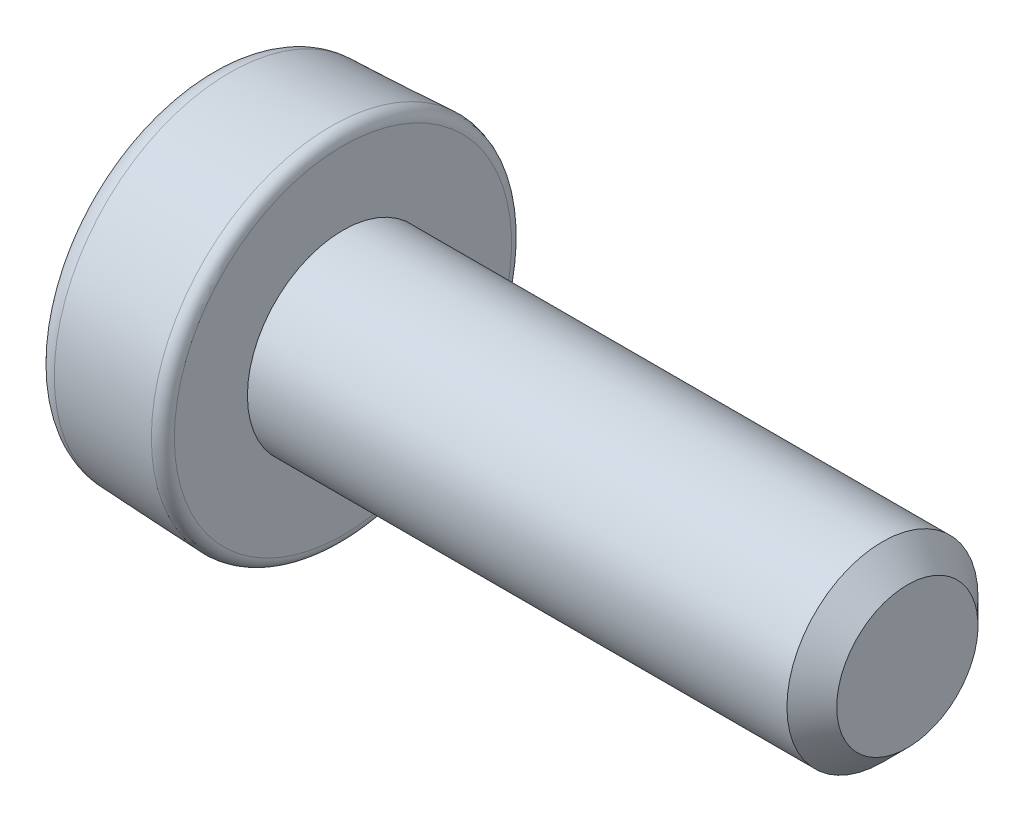
from build123d import *

# Parameters (mm, degrees)
ESQUISSE2_W                  = 0.3
ESQUISSE2_H                  = 0.8
EXTRUSION1_DEPTH             = 0.3
R_P_TITION_CIRCULAIRE1_COUNT = 4
CHANFREIN1_SIZE              = 0.2


with BuildPart() as part:
    # Esquisse1 → Révolution1 (revolve)
    with BuildSketch(Plane.XY, mode=Mode.PRIVATE) as r_volution1_sk:
        with BuildLine():
            Line((5.021607474, 0), (5.021607474, 0.628392526))
            Line((5.021607474, 0.628392526), (4.8, 0.85))
            Line((4.8, 0.85), (0, 0.85))
            Line((0, 0.85), (0, 1.50010144))
            ThreePointArc((0, 1.50010144), (-0.030899737, 1.572386664), (-0.104503073, 1.6))
            Line((-0.104503073, 1.6), (-1.009006147, 1.559228203))
            ThreePointArc((-1.009006147, 1.559228203), (-1.144570449, 1.497631608), (-1.2, 1.359431083))
            Line((-1.2, 1.359431083), (-1.2, 0))
            Line((-1.2, 0), (5.021607474, 0))
        make_face()
    revolve(r_volution1_sk.sketch.rotate(Axis((-2.783918663, 0, 0), (1, 0, 0)), 90), axis=Axis((-2.783918663, 0, 0), (1, 0, 0)))  # turned: the seam where the file's is

    # Esquisse2 → Extrusion1 (cut)
    with BuildSketch(Plane.ZY.offset(1.2)):
        with Locations((0, 0.4)):
            Rectangle(ESQUISSE2_W, ESQUISSE2_H)
    extrusion1 = extrude(amount=-EXTRUSION1_DEPTH, mode=Mode.SUBTRACT)

    # Répétition circulaire1: Extrusion1 ×4 about axis
    r_p_tition_circulaire1_axis = Axis((0, 0, 0), (1, 0, 0))
    for i in range(1, R_P_TITION_CIRCULAIRE1_COUNT):
        add(extrusion1.rotate(r_p_tition_circulaire1_axis, i * 360 / R_P_TITION_CIRCULAIRE1_COUNT), mode=Mode.SUBTRACT)

    # Chanfrein1
    chanfrein1_edges = [part.edges().sort_by_distance(p)[0] for p in [
        (-1.05, 0.15, -0.15),
        (-1.05, 0.15, 0.15),
        (-1.05, -0.15, -0.15),
        (-1.05, -0.15, 0.15),
    ]]
    chamfer(chanfrein1_edges, length=CHANFREIN1_SIZE)


solid = part.part
